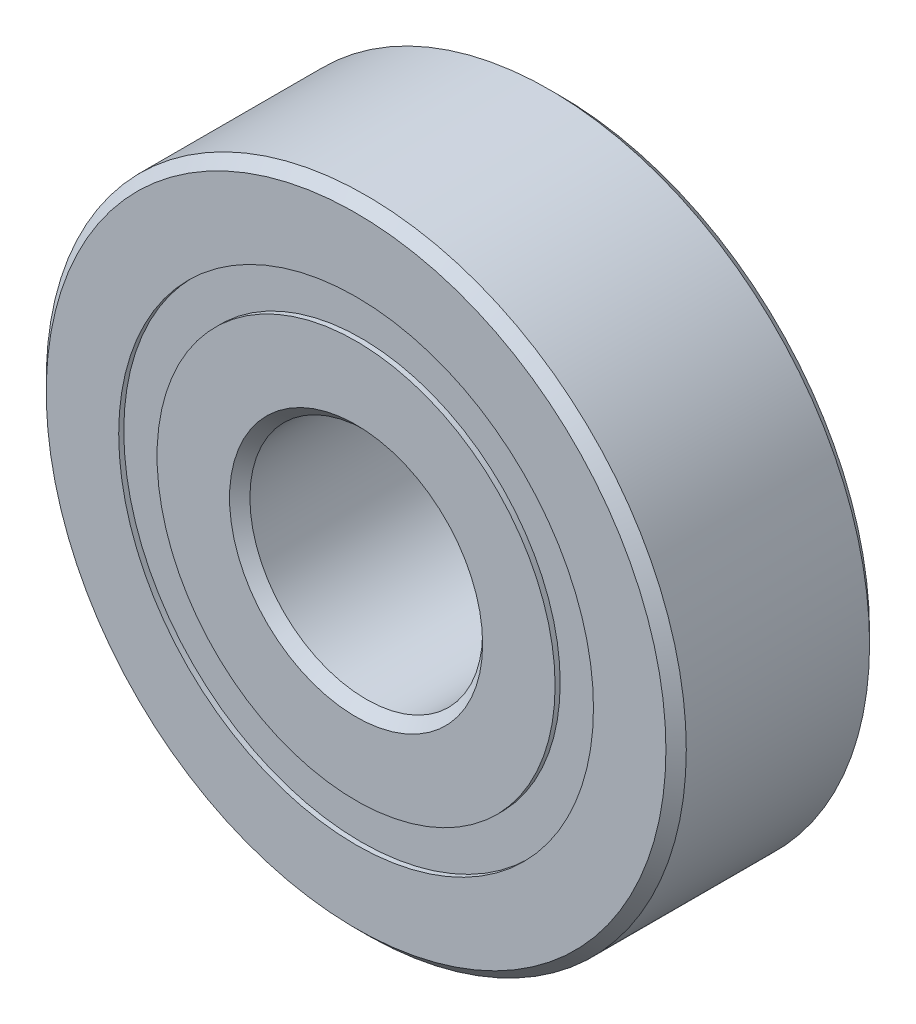
from build123d import *

# Parameters (mm, degrees)
CIRPATTERN1_COUNT = 14
SKETCH6_W         = 1.635478413
SKETCH6_H         = 1.318681318


with BuildPart() as part:
    # Sketch1 → Revolve1 (revolve)
    with BuildSketch(Plane(origin=(0, 0, 0), x_dir=(0, 0, -1), z_dir=(1, 0, 0))):
        with BuildLine():
            Line((3.15, 11), (-3.15, 11))
            Line((-3.15, 11), (-3.5, 10.65))
            Line((-3.5, 10.65), (-3.5, 8.159340659))
            Line((-3.5, 8.159340659), (-1.555555556, 8.159340659))
            ThreePointArc((-1.555555556, 8.159340659), (0, 9.189521587), (1.555555556, 8.159340659))
            Line((1.555555556, 8.159340659), (3.5, 8.159340659))
            Line((3.5, 8.159340659), (3.5, 10.65))
            Line((3.5, 10.65), (3.15, 11))
        make_face()
    revolve(axis=Axis((0, 0, 3.5), (0, 0, -1)))


with BuildPart() as body_2:
    # Sketch3 → Revolve3 (revolve)
    with BuildSketch(Plane(origin=(0, 0, 0), x_dir=(0, 0, -1), z_dir=(1, 0, 0))):
        with BuildLine():
            Line((-3.5, 6.840659341), (-1.555555556, 6.840659341))
            ThreePointArc((-1.555555556, 6.840659341), (0, 5.810478413), (1.555555556, 6.840659341))
            Line((1.555555556, 6.840659341), (3.5, 6.840659341))
            Line((3.5, 6.840659341), (3.5, 4.35))
            Line((3.5, 4.35), (3.15, 4))
            Line((3.15, 4), (-3.15, 4))
            Line((-3.15, 4), (-3.5, 4.35))
            Line((-3.5, 4.35), (-3.5, 6.840659341))
        make_face()
    revolve(axis=Axis((0, 0, 3.5), (0, 0, -1)))


with BuildPart() as body_3:
    # Sketch4 → Revolve4 (revolve)
    with BuildSketch(Plane(origin=(0, 0, 0), x_dir=(0, 0, -1), z_dir=(1, 0, 0))):
        with BuildLine():
            Line((-1.689521587, 7.5), (1.689521587, 7.5))
            ThreePointArc((1.689521587, 7.5), (0, 9.189521587), (-1.689521587, 7.5))
        make_face()
    revolve(axis=Axis((0, 7.5, 1.689521587), (0, 0, -1)))


with BuildPart() as cirpattern1_1:
    # CirPattern1: pattern copy
    add(body_3.part.rotate(Axis((0, 0, -3.5), (0, 0, 1)), 1 * 360 / CIRPATTERN1_COUNT))


with BuildPart() as cirpattern1_2:
    # CirPattern1: pattern copy
    add(body_3.part.rotate(Axis((0, 0, -3.5), (0, 0, 1)), 2 * 360 / CIRPATTERN1_COUNT))


with BuildPart() as cirpattern1_3:
    # CirPattern1: pattern copy
    add(body_3.part.rotate(Axis((0, 0, -3.5), (0, 0, 1)), 3 * 360 / CIRPATTERN1_COUNT))


with BuildPart() as cirpattern1_4:
    # CirPattern1: pattern copy
    add(body_3.part.rotate(Axis((0, 0, -3.5), (0, 0, 1)), 4 * 360 / CIRPATTERN1_COUNT))


with BuildPart() as cirpattern1_5:
    # CirPattern1: pattern copy
    add(body_3.part.rotate(Axis((0, 0, -3.5), (0, 0, 1)), 5 * 360 / CIRPATTERN1_COUNT))


with BuildPart() as cirpattern1_6:
    # CirPattern1: pattern copy
    add(body_3.part.rotate(Axis((0, 0, -3.5), (0, 0, 1)), 6 * 360 / CIRPATTERN1_COUNT))


with BuildPart() as cirpattern1_7:
    # CirPattern1: pattern copy
    add(body_3.part.rotate(Axis((0, 0, -3.5), (0, 0, 1)), 7 * 360 / CIRPATTERN1_COUNT))


with BuildPart() as cirpattern1_8:
    # CirPattern1: pattern copy
    add(body_3.part.rotate(Axis((0, 0, -3.5), (0, 0, 1)), 8 * 360 / CIRPATTERN1_COUNT))


with BuildPart() as cirpattern1_9:
    # CirPattern1: pattern copy
    add(body_3.part.rotate(Axis((0, 0, -3.5), (0, 0, 1)), 9 * 360 / CIRPATTERN1_COUNT))


with BuildPart() as cirpattern1_10:
    # CirPattern1: pattern copy
    add(body_3.part.rotate(Axis((0, 0, -3.5), (0, 0, 1)), 10 * 360 / CIRPATTERN1_COUNT))


with BuildPart() as cirpattern1_11:
    # CirPattern1: pattern copy
    add(body_3.part.rotate(Axis((0, 0, -3.5), (0, 0, 1)), 11 * 360 / CIRPATTERN1_COUNT))


with BuildPart() as cirpattern1_12:
    # CirPattern1: pattern copy
    add(body_3.part.rotate(Axis((0, 0, -3.5), (0, 0, 1)), 12 * 360 / CIRPATTERN1_COUNT))


with BuildPart() as cirpattern1_13:
    # CirPattern1: pattern copy
    add(body_3.part.rotate(Axis((0, 0, -3.5), (0, 0, 1)), 13 * 360 / CIRPATTERN1_COUNT))


with BuildPart() as body_17:
    # Sketch6 → Revolve5 (revolve)
    with BuildSketch(Plane(origin=(0, 0, 0), x_dir=(0, 0, -1), z_dir=(1, 0, 0))):
        with Locations((-2.507260794, 7.5)):
            Rectangle(SKETCH6_W, SKETCH6_H)
        with Locations((2.507260794, 7.5)):
            Rectangle(SKETCH6_W, SKETCH6_H)
    revolve(axis=Axis((0, 0, 3.5), (0, 0, -1)))


solid = Compound([part.part, body_2.part, body_3.part, cirpattern1_1.part, cirpattern1_2.part, cirpattern1_3.part, cirpattern1_4.part, cirpattern1_5.part, cirpattern1_6.part, cirpattern1_7.part, cirpattern1_8.part, cirpattern1_9.part, cirpattern1_10.part, cirpattern1_11.part, cirpattern1_12.part, cirpattern1_13.part, body_17.part])
